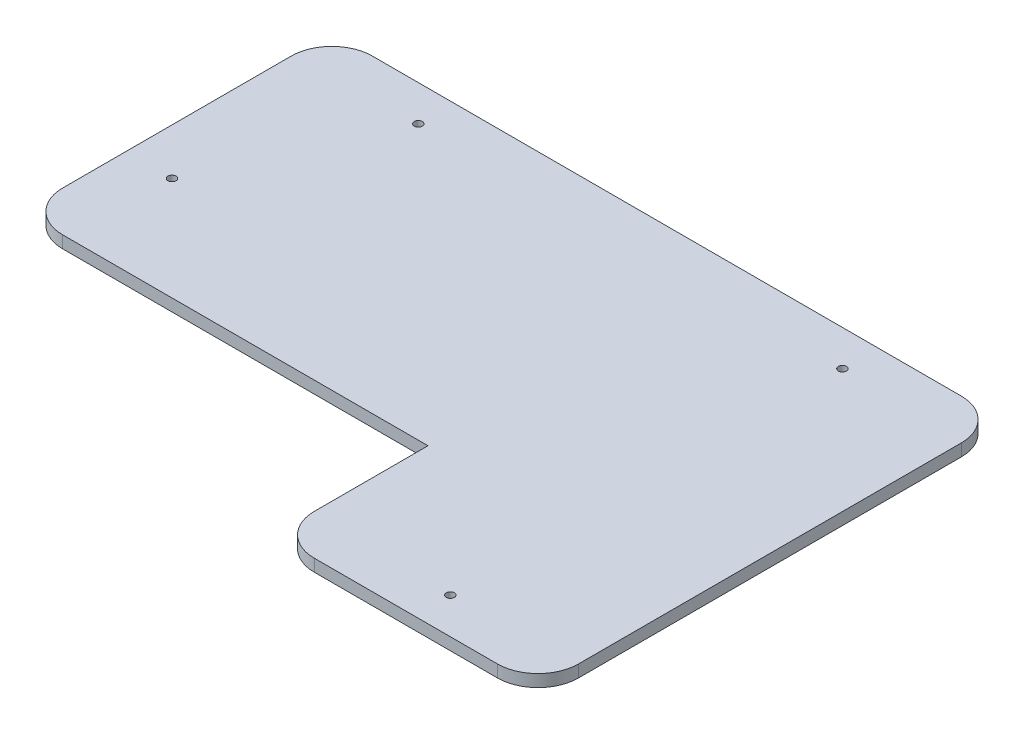
from build123d import *

# Parameters (mm, degrees)
SKETCH1_W           = 165.1
SKETCH1_H           = 114.3
BOSS_EXTRUDE1_DEPTH = 3
SKETCH2_W           = 100
SKETCH2_H           = 38
CUT_EXTRUDE1_DEPTH  = 4
FILLET2_R           = 10
SKETCH3_R           = 1
CUT_EXTRUDE3_DEPTH  = 4


with BuildPart() as part:
    # Sketch1 → Boss-Extrude1 (new body)
    with BuildSketch(Plane(origin=(0, 0, 0), x_dir=(1, 0, 0), z_dir=(0, 1, 0))):
        Rectangle(SKETCH1_W, SKETCH1_H)
    extrude(amount=BOSS_EXTRUDE1_DEPTH)

    # Sketch2 → Cut-Extrude1 (cut, through all)
    with BuildSketch(Plane(origin=(0, 3, 0), x_dir=(1, 0, 0), z_dir=(0, 1, 0))):
        with Locations((-32.55, -38.15)):
            Rectangle(SKETCH2_W, SKETCH2_H)
    extrude(amount=-CUT_EXTRUDE1_DEPTH, mode=Mode.SUBTRACT)

    # Fillet2
    fillet2_edges = [part.edges().sort_by_distance(p)[0] for p in [
        (-82.55, 1.5, 19.15),
        (17.45, 1.5, 57.15),
        (-82.55, 1.5, -57.15),
        (82.55, 1.5, -57.15),
        (82.55, 1.5, 57.15),
    ]]
    fillet(fillet2_edges, radius=FILLET2_R)

    # Sketch3 → Cut-Extrude3 (cut, through all)
    with BuildSketch(Plane(origin=(0, 3, 0), x_dir=(1, 0, 0), z_dir=(0, 1, 0))):
        with Locations((-52.43, 48.34)):
            Circle(SKETCH3_R)
        with Locations((-71.12, 6.35)):
            Circle(SKETCH3_R)
        with Locations((52.07, 48.34)):
            Circle(SKETCH3_R)
        with Locations((52.07, -48.26)):
            Circle(SKETCH3_R)
    extrude(amount=-CUT_EXTRUDE3_DEPTH, mode=Mode.SUBTRACT)


solid = part.part
